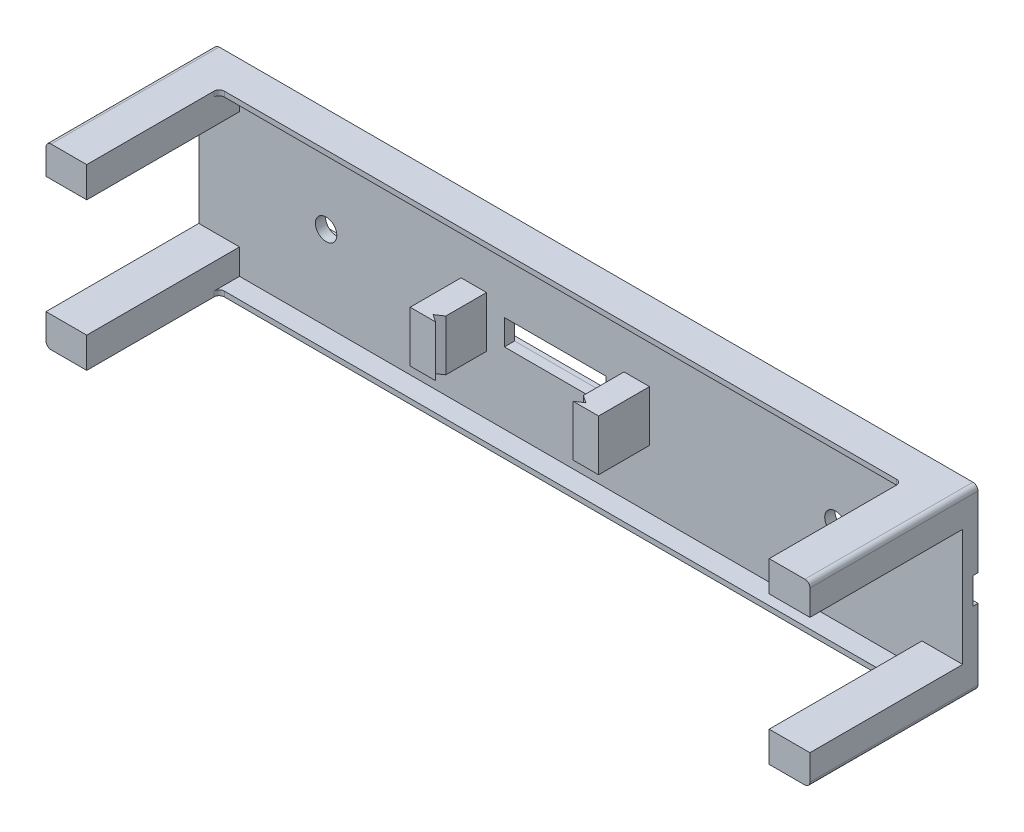
from build123d import *

# Parameters (mm, degrees)
SKICA1_W                 = 150
SKICA1_H                 = 35
P_IDAT_VYSUNUT_M2_DEPTH  = 3
SKICA4_W                 = 20
SKICA4_H                 = 5
ODEBRAT_VYSUNUT_M1_DEPTH = 2
SKICA5_W                 = 150
SKICA5_H                 = 5.2
ODEBRAT_VYSUNUT_M3_DEPTH = 1
SKICA7_R                 = 2.1
ODEBRAT_VYSUNUT_M4_DEPTH = 3
SKICA8_W                 = 8
SKICA8_H                 = 6
P_IDAT_VYSUNUT_M4_DEPTH  = 30
ZAOBLIT1_R               = 1
SKICA9_W                 = 134
SKICA9_H                 = 1
P_IDAT_VYSUNUT_M5_DEPTH  = 4
ZAOBLIT2_R               = 1
SKICA10_W                = 5
SKICA10_H                = 10
P_IDAT_VYSUNUT_M6_DEPTH  = 10
ODEBRAT_VYSUNUT_M6_DEPTH = 10


with BuildPart() as part:
    # Skica1 → Přidat vysunutím2 (new body)
    with BuildSketch(Plane.XY):
        Rectangle(SKICA1_W, SKICA1_H)
    extrude(amount=P_IDAT_VYSUNUT_M2_DEPTH)

    # Skica4 → Odebrat vysunutím1 (cut)
    with BuildSketch(Plane.XY.offset(3)):
        with Locations((-5, 0)):
            Rectangle(SKICA4_W, SKICA4_H)
    extrude(amount=-ODEBRAT_VYSUNUT_M1_DEPTH, mode=Mode.SUBTRACT)

    # Skica5 → Odebrat vysunutím3 (cut)
    with BuildSketch(Plane(origin=(0, 0, 0), x_dir=(-1, 0, 0), z_dir=(0, 0, -1))):
        Rectangle(SKICA5_W, SKICA5_H)
    extrude(amount=-ODEBRAT_VYSUNUT_M3_DEPTH, mode=Mode.SUBTRACT)

    # Skica7 → Odebrat vysunutím4 (cut, through all)
    with BuildSketch(Plane(origin=(0, 0, 1), x_dir=(-1, 0, 0), z_dir=(0, 0, -1))):
        with Locations((-50, 0)):
            Circle(SKICA7_R)
        with Locations((50, 0)):
            Circle(SKICA7_R)
    extrude(amount=-ODEBRAT_VYSUNUT_M4_DEPTH, mode=Mode.SUBTRACT)

    # Skica8 → Přidat vysunutím4 (add)
    with BuildSketch(Plane.XY.offset(3)):
        with Locations((71, 14.5)):
            Rectangle(SKICA8_W, SKICA8_H)
        with Locations((71, -14.5)):
            Rectangle(SKICA8_W, SKICA8_H)
        with Locations((-71, -14.5)):
            Rectangle(SKICA8_W, SKICA8_H)
        with Locations((-71, 14.5)):
            Rectangle(SKICA8_W, SKICA8_H)
    extrude(amount=P_IDAT_VYSUNUT_M4_DEPTH)

    # Zaoblit1
    zaoblit1_edges = [part.edges().sort_by_distance(p)[0] for p in [
        (75, -17.5, 16.5),
        (75, 17.5, 16.5),
        (-75, 17.5, 16.5),
        (-75, -17.5, 16.5),
    ]]
    fillet(zaoblit1_edges, radius=ZAOBLIT1_R)

    # Skica9 → Přidat vysunutím5 (add)
    with BuildSketch(Plane.XY.offset(3)):
        with Locations((0, 17)):
            Rectangle(SKICA9_W, SKICA9_H)
        with Locations((0, -17)):
            Rectangle(SKICA9_W, SKICA9_H)
    extrude(amount=P_IDAT_VYSUNUT_M5_DEPTH)

    # Zaoblit2
    zaoblit2_edges = [part.edges().sort_by_distance(p)[0] for p in [
        (67, 17, 7),
        (-67, 17, 7),
        (-67, -17, 7),
        (67, -17, 7),
    ]]
    fillet(zaoblit2_edges, radius=ZAOBLIT2_R)

    # Skica10 → Přidat vysunutím6 (add)
    with BuildSketch(Plane.XY.offset(3)):
        with Locations((-21, 0)):
            Rectangle(SKICA10_W, SKICA10_H)
        with Locations((11, 0)):
            Rectangle(SKICA10_W, SKICA10_H)
    extrude(amount=P_IDAT_VYSUNUT_M6_DEPTH)

    # Skica12 → Odebrat vysunutím6 (cut)
    with BuildSketch(Plane(origin=(0, 5, 0), x_dir=(1, 0, 0), z_dir=(0, 1, 0))):
        Polygon((-18.5, -13), (-18.5, -11), (-20, -12), align=None)
        Polygon((8.5, -13), (8.5, -11), (10, -12), align=None)
    extrude(amount=-ODEBRAT_VYSUNUT_M6_DEPTH, mode=Mode.SUBTRACT)


solid = part.part
